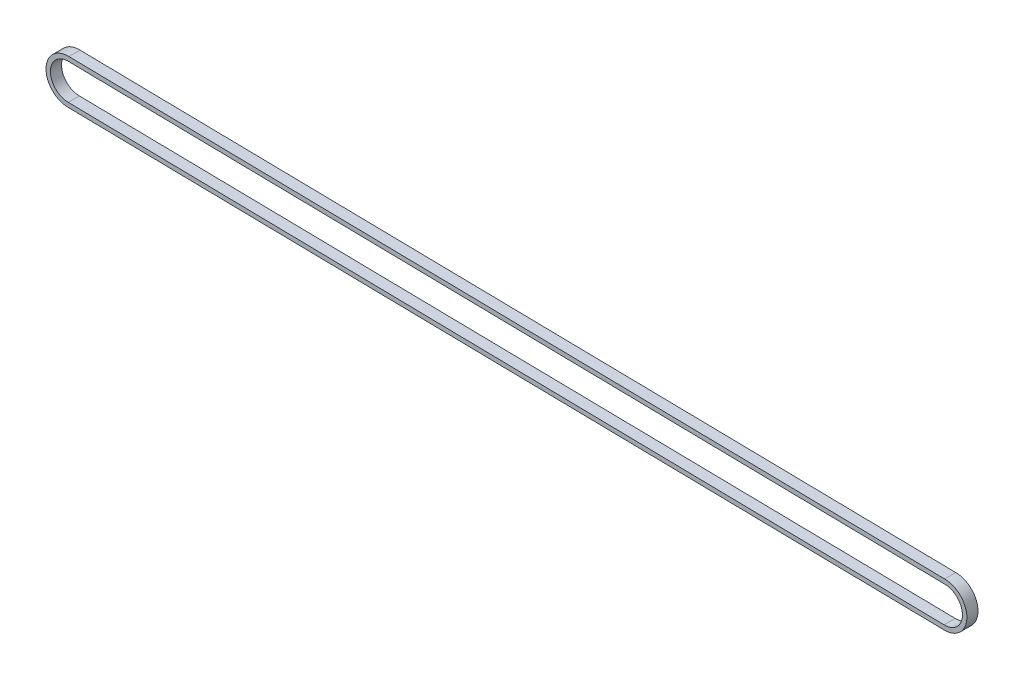
from build123d import *

# Parameters (mm, degrees)
BOSS_EXTRUDE3_DEPTH = 5


with BuildPart() as part:
    # Sketch3 → Boss-Extrude3 (new body)
    with BuildSketch(Plane.XY):
        with BuildLine():
            Line((-32.294867922, 8.197702895), (361.797434094, 1.633206334))
            ThreePointArc((361.797434094, 1.633206334), (371.796047062, -8.533343127), (361.464381374, -18.361245922))
            Line((361.464381374, -18.361245922), (-32.627920642, -11.79674936))
            ThreePointArc((-32.627920642, -11.79674936), (-42.62653361, -1.630199899), (-32.294867922, 8.197702895))
        make_face()
        with BuildLine():
            Line((-32.627920642, -9.79674936), (361.530991918, -16.36235547))
            ThreePointArc((361.530991918, -16.36235547), (369.796324468, -8.500033235), (361.797434094, -0.366793666))
            Line((361.797434094, -0.366793666), (-32.361478466, 6.198812444))
            ThreePointArc((-32.361478466, 6.198812444), (-40.626811016, -1.663509791), (-32.627920642, -9.79674936))
        make_face(mode=Mode.SUBTRACT)
    extrude(amount=BOSS_EXTRUDE3_DEPTH)


solid = part.part
